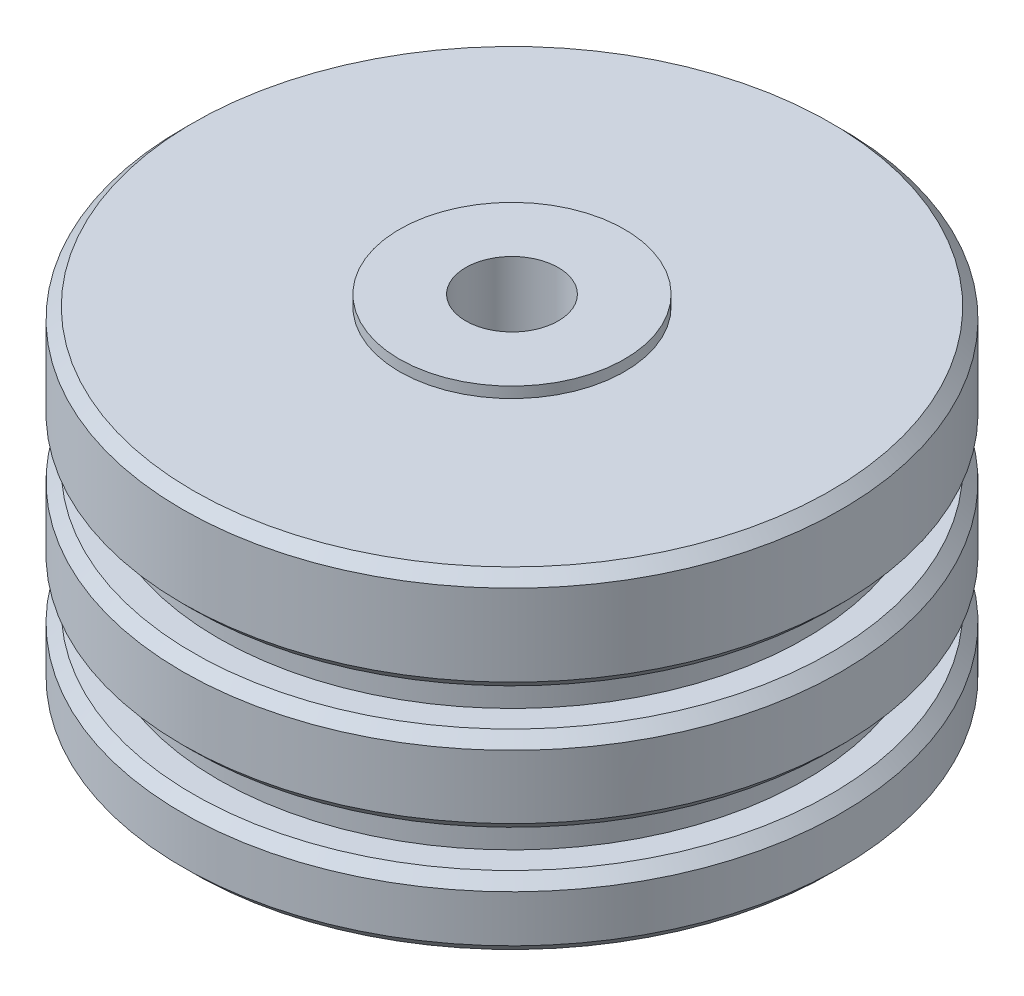
from build123d import *

# Parameters (mm, degrees)
F_1_4_CLEARANCE_HOLE1_D = 6.5278
CHAMFER1_SIZE           = 0.762


with BuildPart() as part:
    # Sketch1 → Revolve1 (revolve)
    with BuildSketch(Plane.XY):
        Polygon((7.9375, 0.762), (7.9375, 0), (0, 0), (0, 24.892), (7.9375, 24.892), (7.9375, 24.13), (23.241, 24.13), (23.241, 16.8656), (20.701, 16.8656), (20.701, 14.226799969), (23.241, 14.226799969), (23.241, 8.226800031), (20.701, 8.226800031), (20.701, 5.588), (23.241, 5.588), (23.241, 0.762), align=None)
    revolve(axis=Axis((0, 24.892, 0), (0, -1, 0)))

    # 1/4 Clearance Hole1 (through all)
    with Locations(Plane(origin=(0, 24.892, 0), x_dir=(1, 0, 0), z_dir=(0, 1, 0))):
        with Locations((0, 0)):
            Hole(F_1_4_CLEARANCE_HOLE1_D / 2)

    # Chamfer1
    chamfer1_edges = [part.edges().sort_by_distance(p)[0] for p in [
        (-23.241, 24.13, 0),
        (-23.241, 16.8656, 0),
        (-23.241, 14.226799969, 0),
        (-23.241, 8.226800031, 0),
        (-23.241, 5.588, 0),
        (-23.241, 0.762, 0),
    ]]
    chamfer(chamfer1_edges, length=CHAMFER1_SIZE)


solid = part.part
